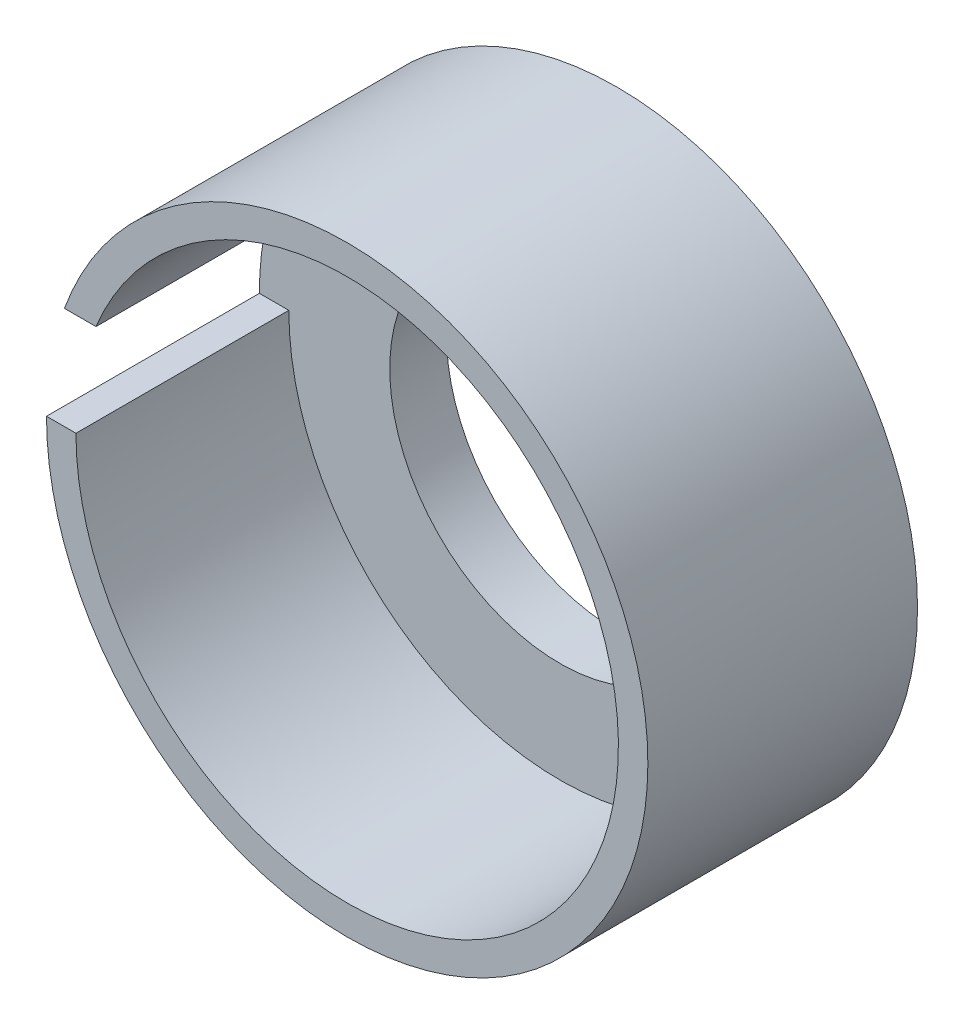
from build123d import *

# Parameters (mm, degrees)
SKETCH1_R           = 42.375
BOSS_EXTRUDE1_DEPTH = 8
BOSS_EXTRUDE2_DEPTH = 30
SKETCH4_R           = 24
CUT_EXTRUDE1_DEPTH  = 20


with BuildPart() as part:
    # Sketch1 → Boss-Extrude1 (new body)
    with BuildSketch(Plane.XY):
        Circle(SKETCH1_R)
    extrude(amount=BOSS_EXTRUDE1_DEPTH)

    # Sketch2 → Boss-Extrude2 (add)
    with BuildSketch(Plane.XY.offset(8)):
        with BuildLine():
            ThreePointArc((38.225, 0), (0, -38.225), (-38.225, 0))
            Line((-38.225, 0), (-42.375, 0))
            ThreePointArc((-42.375, 0), (0, -42.375), (42.375, 0))
            ThreePointArc((42.375, 0), (7.323876107, 41.737291045), (-39.843358172, 14.42731557))
            Line((-39.843358172, 14.42731557), (-35.397785106, 14.42731557))
            ThreePointArc((-35.397785106, 14.42731557), (7.35086013, 37.511537963), (38.225, 0))
        make_face()
    extrude(amount=BOSS_EXTRUDE2_DEPTH)

    # Sketch4 → Cut-Extrude1 (cut)
    with BuildSketch(Plane.XY.offset(8)):
        Circle(SKETCH4_R)
    extrude(amount=-CUT_EXTRUDE1_DEPTH, mode=Mode.SUBTRACT)


solid = part.part
